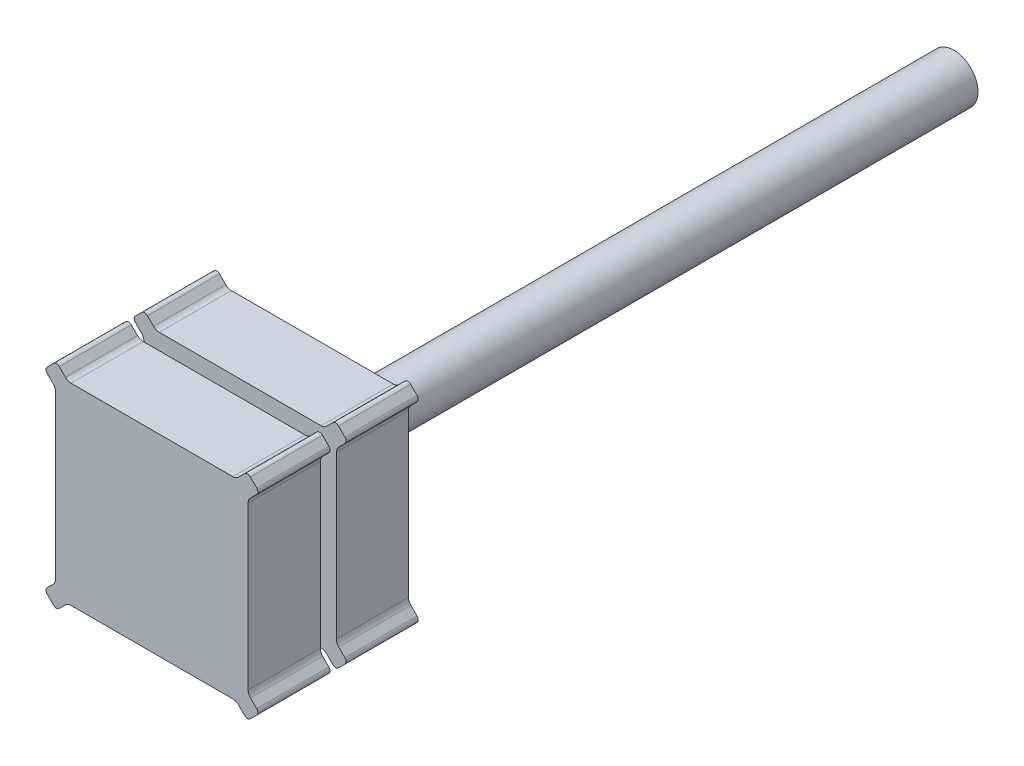
from build123d import *

# Parameters (mm, degrees)
BOSS_EXTRUDE1_DEPTH = 20
SKETCH3_R           = 3
BOSS_EXTRUDE2_DEPTH = 80
SKETCH5_R           = 20
SKETCH5_R_2         = 4
CUT_EXTRUDE1_DEPTH  = 2


with BuildPart() as part:
    # Sketch1 → Boss-Extrude1 (new body)
    with BuildSketch(Plane.XY):
        with BuildLine():
            Line((-13.060660172, 11.560660172), (-12.292893219, 10.792893219))
            ThreePointArc((-12.292893219, 10.792893219), (-12.076120467, 10.46846987), (-12, 10.085786438))
            Line((-12, 10.085786438), (-12, -10.085786438))
            ThreePointArc((-12, -10.085786438), (-12.076120467, -10.46846987), (-12.292893219, -10.792893219))
            Line((-12.292893219, -10.792893219), (-13.060660172, -11.560660172))
            ThreePointArc((-13.060660172, -11.560660172), (-13.207106781, -11.914213562), (-13.060660172, -12.267766953))
            Line((-13.060660172, -12.267766953), (-12.267766953, -13.060660172))
            ThreePointArc((-12.267766953, -13.060660172), (-11.914213562, -13.207106781), (-11.560660172, -13.060660172))
            Line((-11.560660172, -13.060660172), (-10.792893219, -12.292893219))
            ThreePointArc((-10.792893219, -12.292893219), (-10.46846987, -12.076120467), (-10.085786438, -12))
            Line((-10.085786438, -12), (10.085786438, -12))
            ThreePointArc((10.085786438, -12), (10.46846987, -12.076120467), (10.792893219, -12.292893219))
            Line((10.792893219, -12.292893219), (11.560660172, -13.060660172))
            ThreePointArc((11.560660172, -13.060660172), (11.914213562, -13.207106781), (12.267766953, -13.060660172))
            Line((12.267766953, -13.060660172), (13.060660172, -12.267766953))
            ThreePointArc((13.060660172, -12.267766953), (13.207106781, -11.914213562), (13.060660172, -11.560660172))
            Line((13.060660172, -11.560660172), (12.292893219, -10.792893219))
            ThreePointArc((12.292893219, -10.792893219), (12.076120467, -10.46846987), (12, -10.085786438))
            Line((12, -10.085786438), (12, 10.085786438))
            ThreePointArc((12, 10.085786438), (12.076120467, 10.46846987), (12.292893219, 10.792893219))
            Line((12.292893219, 10.792893219), (13.060660172, 11.560660172))
            ThreePointArc((13.060660172, 11.560660172), (13.207106781, 11.914213562), (13.060660172, 12.267766953))
            Line((13.060660172, 12.267766953), (12.267766953, 13.060660172))
            ThreePointArc((12.267766953, 13.060660172), (11.914213562, 13.207106781), (11.560660172, 13.060660172))
            Line((11.560660172, 13.060660172), (10.792893219, 12.292893219))
            ThreePointArc((10.792893219, 12.292893219), (10.46846987, 12.076120467), (10.085786438, 12))
            Line((10.085786438, 12), (-10.085786438, 12))
            ThreePointArc((-10.085786438, 12), (-10.46846987, 12.076120467), (-10.792893219, 12.292893219))
            Line((-10.792893219, 12.292893219), (-11.560660172, 13.060660172))
            ThreePointArc((-11.560660172, 13.060660172), (-11.914213562, 13.207106781), (-12.267766953, 13.060660172))
            Line((-12.267766953, 13.060660172), (-13.060660172, 12.267766953))
            ThreePointArc((-13.060660172, 12.267766953), (-13.207106781, 11.914213562), (-13.060660172, 11.560660172))
        make_face()
    extrude(amount=BOSS_EXTRUDE1_DEPTH)

    # Sketch3 → Boss-Extrude2 (add)
    with BuildSketch(Plane(origin=(0, 0, 0), x_dir=(-1, 0, 0), z_dir=(0, 0, -1))):
        Circle(SKETCH3_R)
    extrude(amount=BOSS_EXTRUDE2_DEPTH)

    # Sketch5 → Cut-Extrude1 (cut)
    with BuildSketch(Plane.XY.offset(11)):
        Circle(SKETCH5_R)
        Circle(SKETCH5_R_2, mode=Mode.SUBTRACT)
    extrude(amount=-CUT_EXTRUDE1_DEPTH, mode=Mode.SUBTRACT)


solid = part.part
